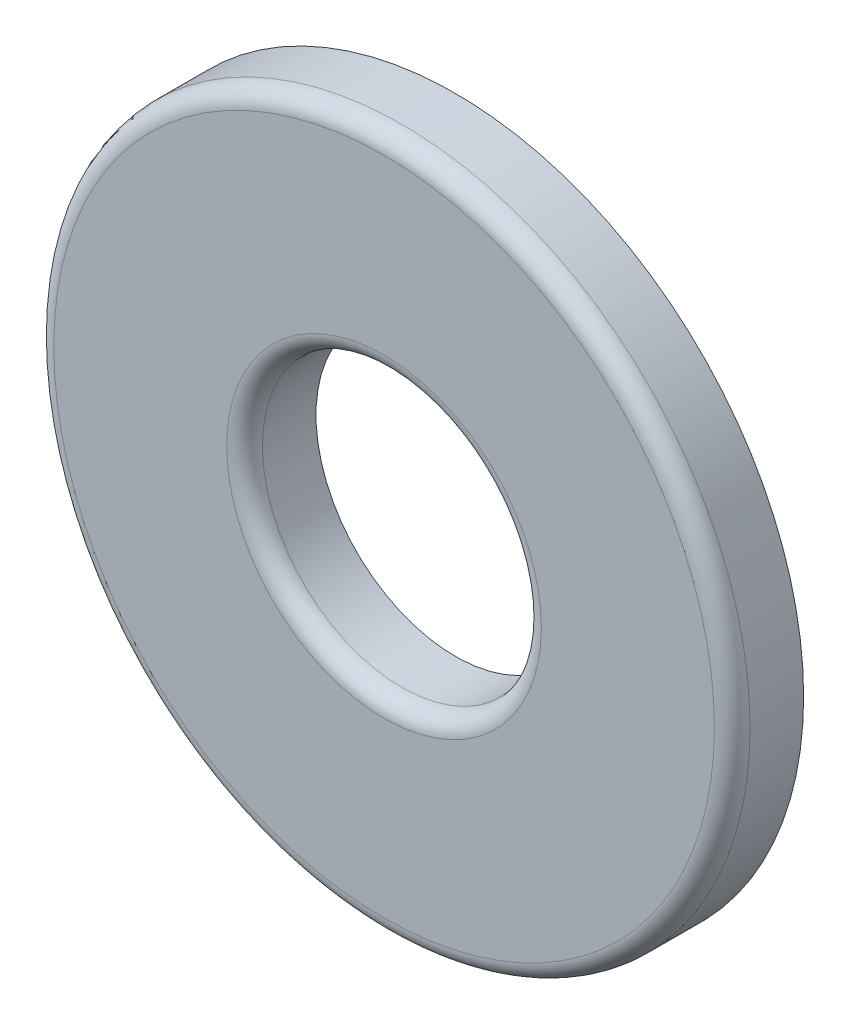
from build123d import *

# Parameters (mm, degrees)
SKETCH3_R                = 3.9624
SKETCH3_R_2              = 1.5875
BOSS_EXTRUDE1_DEPTH      = 0.4064
BOSS_EXTRUDE1_DEPTH_BACK = 0.4064
FILLET1_R                = 0.2032


with BuildPart() as part:
    # Sketch3 → Boss-Extrude1 (new body, two sides)
    with BuildSketch(Plane.XY) as boss_extrude1_sk:
        Circle(SKETCH3_R)
        Circle(SKETCH3_R_2, mode=Mode.SUBTRACT)
    extrude(amount=BOSS_EXTRUDE1_DEPTH)
    extrude(boss_extrude1_sk.sketch, amount=-BOSS_EXTRUDE1_DEPTH_BACK)

    # Fillet1
    fillet1_edges = [part.edges().sort_by_distance(p)[0] for p in [
        (-3.9624, 0, 0.4064),
        (-1.5875, 0, 0.4064),
    ]]
    fillet(fillet1_edges, radius=FILLET1_R)


solid = part.part
